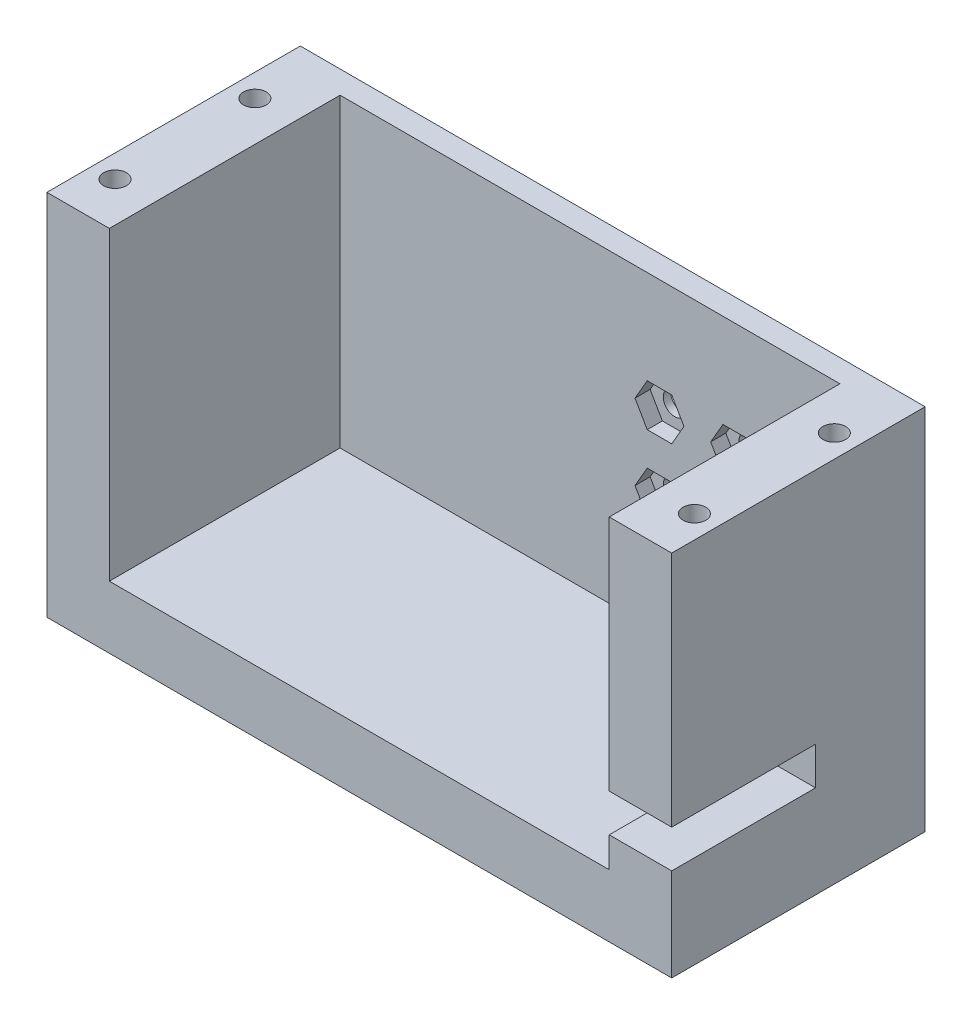
from build123d import *

# Parameters (mm, degrees)
EXTRUDE_1_DEPTH     = 30.48
SKETCH_4_R          = 3.302
EXTRUDE_2_DEPTH     = 6.12463
SKETCH_5_W          = 82.55
SKETCH_5_H          = 48.620400001
EXTRUDE_3_DEPTH     = 3
SKETCH_6_R          = 1.5
CUT_EXTRUDE_1_DEPTH = 3
SKETCH_7_R          = 1.5
CUT_EXTRUDE_2_DEPTH = 2
SKETCH_8_R          = 1.5
CUT_EXTRUDE_3_DEPTH = 10
SKETCH_9_W          = 8.255
SKETCH_9_H          = 5
CUT_EXTRUDE_4_DEPTH = 19


with BuildPart() as part:
    # 스케치3 → 보스-돌출1 (new body)
    with BuildSketch(Plane.XY):
        Polygon((21517.522317655, 8422.852866974), (21525.777317655, 8422.852866974), (21525.777317655, 8382.487466973), (21591.817317655, 8382.487466973), (21591.817317655, 8422.852866974), (21600.072317655, 8422.852866974), (21600.072317655, 8374.232466973), (21517.522317655, 8374.232466973), align=None)
    extrude(amount=EXTRUDE_1_DEPTH)

    # 스케치4 → 보스-돌출2 (add)
    with BuildSketch(Plane(origin=(0, 8374.232466973, 0), x_dir=(-1, 0, 0), z_dir=(0, -1, 0))):
        with Locations((-21576.717457655, -15.24)):
            Circle(SKETCH_4_R)
    extrude(amount=EXTRUDE_2_DEPTH)

    # 스케치5 → 보스-돌출3 (add)
    with BuildSketch(Plane(origin=(0, 0, 0), x_dir=(-1, 0, 0), z_dir=(0, 0, -1))):
        with Locations((-21558.797317655, 8398.542666974)):
            Rectangle(SKETCH_5_W, SKETCH_5_H)
    extrude(amount=EXTRUDE_3_DEPTH)

    # 스케치6 → 컷-돌출1 (cut)
    with BuildSketch(Plane.XY):
        with Locations((21577.97657564, 8407.672466973)):
            Circle(SKETCH_6_R)
        with Locations((21567.97657564, 8407.672466973)):
            Circle(SKETCH_6_R)
        with Locations((21567.97657564, 8397.672466973)):
            Circle(SKETCH_6_R)
        with Locations((21577.97657564, 8397.672466973)):
            Circle(SKETCH_6_R)
    extrude(amount=-CUT_EXTRUDE_1_DEPTH, mode=Mode.SUBTRACT)

    # 스케치7 → 컷-돌출2 (cut)
    with BuildSketch(Plane.XY):
        Polygon((21569.593155483, 8410.472467064), (21566.359995798, 8410.472467064), (21564.743415955, 8407.672466973), (21566.359995798, 8404.872466883), (21569.593155483, 8404.872466883), (21571.209735325, 8407.672466973), align=None)
        with Locations((21567.97657564, 8407.672466973)):
            Circle(SKETCH_7_R, mode=Mode.SUBTRACT)
        Polygon((21569.593155483, 8400.472467064), (21566.359995798, 8400.472467064), (21564.743415955, 8397.672466973), (21566.359995798, 8394.872466883), (21569.593155483, 8394.872466883), (21571.209735325, 8397.672466973), align=None)
        with Locations((21567.97657564, 8397.672466973)):
            Circle(SKETCH_7_R, mode=Mode.SUBTRACT)
        Polygon((21579.593155483, 8400.472467064), (21576.359995798, 8400.472467064), (21574.743415955, 8397.672466973), (21576.359995798, 8394.872466883), (21579.593155483, 8394.872466883), (21581.209735325, 8397.672466973), align=None)
        with Locations((21577.97657564, 8397.672466973)):
            Circle(SKETCH_7_R, mode=Mode.SUBTRACT)
        Polygon((21579.593155483, 8410.472467064), (21576.359995798, 8410.472467064), (21574.743415955, 8407.672466973), (21576.359995798, 8404.872466883), (21579.593155483, 8404.872466883), (21581.209735325, 8407.672466973), align=None)
        with Locations((21577.97657564, 8407.672466973)):
            Circle(SKETCH_7_R, mode=Mode.SUBTRACT)
    extrude(amount=-CUT_EXTRUDE_2_DEPTH, mode=Mode.SUBTRACT)

    # 스케치8 → 컷-돌출3 (cut)
    with BuildSketch(Plane(origin=(0, 8422.852866974, 0), x_dir=(1, 0, 0), z_dir=(0, 1, 0))):
        with Locations((21597.072317655, -6)):
            Circle(SKETCH_8_R)
        with Locations((21597.072317655, -24.48)):
            Circle(SKETCH_8_R)
        with Locations((21520.522317655, -24.48)):
            Circle(SKETCH_8_R)
        with Locations((21520.522317655, -6)):
            Circle(SKETCH_8_R)
    extrude(amount=-CUT_EXTRUDE_3_DEPTH, mode=Mode.SUBTRACT)

    # 스케치9 → 컷-돌출4 (cut)
    with BuildSketch(Plane.XY.offset(30.48)):
        with Locations((21595.944817655, 8388.987466973)):
            Rectangle(SKETCH_9_W, SKETCH_9_H)
    extrude(amount=-CUT_EXTRUDE_4_DEPTH, mode=Mode.SUBTRACT)


solid = part.part
